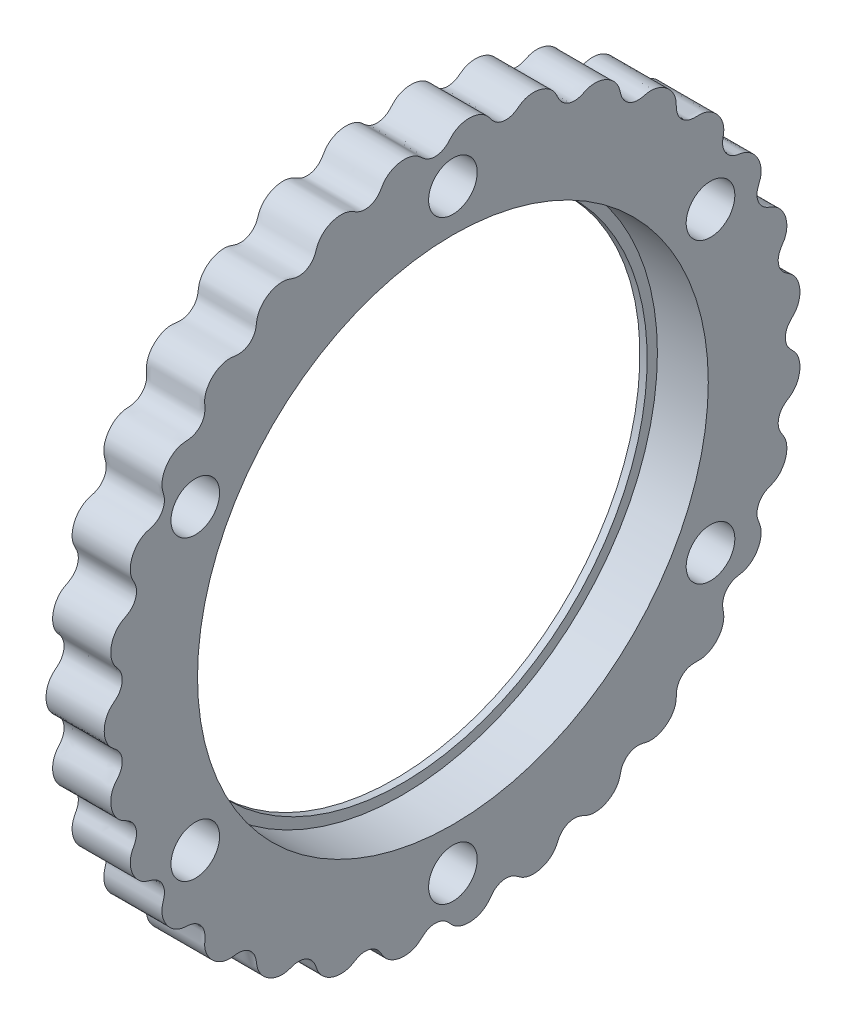
from build123d import *

# Parameters (mm, degrees)
BOSS_EXTRUDE1_START = 8.2233
SKETCH7_R           = 49.999999949
SKETCH7_R_2         = 4.7625
BOSS_EXTRUDE1_DEPTH = 11.38825


with BuildPart() as part:
    # Sketch6 → Revolve2 (revolve)
    with BuildSketch(Plane.XY):
        Polygon((19.611549931, 53.475999982), (19.611549931, 49.999999949), (9.651550039, 49.999999949), (9.651550039, 47.999999885), (8.223300038, 47.999999885), (8.223300038, 53.475999982), align=None)
    revolve(axis=Axis((0, 0, 0), (1, 0, 0)))

    # Sketch7 → Boss-Extrude1 (add)
    with BuildSketch(Plane(origin=(0, 0, 0), x_dir=(0, 0, -1), z_dir=(1, 0, 0)).offset(BOSS_EXTRUDE1_START)):
        with BuildLine():
            ThreePointArc((65.098780627, 0.27709471), (65.090321324, 0.138662117), (65.0875, 0))
            add(Edge.make_bspline(
                [(65.0875, 0), (65.0875, -0.208527214), (65.133599927, -0.609335641), (65.319634448, -1.45231409), (65.738958841, -2.044732783), (66.24197289, -2.634092343), (66.729882451, -3.091590187), (67.173103451, -3.625748901), (67.521923591, -4.256575501), (67.839915149, -5.13544118), (68.004224364, -6.262937423), (67.904252833, -7.395632118), (67.553421572, -8.463998502), (67.116556617, -9.243694687), (66.700058211, -9.785186855), (66.222308814, -10.231621663), (65.704158699, -10.582424575), (65.103322655, -10.967082845), (64.501549767, -11.498449482), (63.983590957, -12.254130319), (63.70763756, -13.098064846), (63.657719494, -13.866495058), (63.750855089, -14.554140201), (63.92789892, -15.134430068), (64.223112812, -15.709945145), (64.617055615, -16.274936704), (64.985907802, -16.884841215), (65.240485751, -17.579507616), (65.377214038, -18.331533392), (65.395270395, -19.11878896), (65.288777476, -19.945414815), (65.041620136, -20.788659452), (64.637922844, -21.623526922), (64.059495427, -22.401870056), (63.369916617, -23.037205503), (62.588760672, -23.470131774), (61.781981694, -23.746366631), (61.057767436, -24.118281418), (60.365794498, -24.706446383), (59.881634988, -25.407800925), (59.60933356, -26.15271169), (59.512709195, -26.91906777), (59.549810856, -27.588792892), (59.727266465, -28.278117532), (60.028942229, -28.968696408), (60.283097371, -29.702506941), (60.375831708, -30.502647102), (60.327159357, -31.328015311), (60.134956117, -32.157051395), (59.818344324, -32.932112808), (59.394478631, -33.638225664), (58.878075878, -34.262658017), (58.282418746, -34.791671978), (57.629949513, -35.20749347), (56.937792078, -35.491836111), (56.230514956, -35.633287995), (55.542462827, -35.743578453), (54.919227561, -35.945127455), (54.378361853, -36.235677848), (53.822571133, -36.664704513), (53.337918924, -37.227949926), (52.963453406, -37.963303629), (52.775433567, -38.847737386), (52.800223231, -39.694882195), (52.9662349, -40.433452061), (53.050052152, -41.095329294), (53.029920535, -41.674115611), (52.955631084, -42.160086027), (52.799880464, -42.75417159), (52.520389982, -43.437088414), (52.012298448, -44.274269508), (51.299918585, -45.032303579), (50.50742412, -45.599646966), (49.68883197, -45.974894374), (49.000137068, -46.172572319), (48.29403395, -46.238592897), (47.590293926, -46.202114971), (46.932560656, -46.210169697), (46.330103519, -46.323451249), (45.675208144, -46.561007427), (45.021374503, -46.957177111), (44.403479518, -47.583512755), (43.971316932, -48.390947227), (43.770608178, -49.182231329), (43.733836837, -49.918141941), (43.730202918, -50.581569376), (43.633360265, -51.260840719), (43.407861863, -51.935688033), (42.984623071, -52.755634025), (42.266810947, -53.65063513), (41.353321421, -54.359912682), (40.30073694, -54.836464715), (39.399602441, -55.039136925), (38.710911895, -55.087053199), (38.067869129, -55.022055726), (37.47907552, -54.881349135), (36.794495983, -54.723810858), (35.992455451, -54.67858833), (35.090739907, -54.852154256), (34.298120904, -55.264775421), (33.725724994, -55.77766287), (33.314091426, -56.326030843), (33.034525654, -56.85613165), (32.83918341, -57.464305795), (32.705345325, -58.131774444), (32.505687509, -58.807194553), (32.169196217, -59.456351497), (31.716094127, -60.059960046), (31.158665936, -60.602666075), (30.485664644, -61.08648281), (29.699854257, -61.483005172), (28.808796326, -61.758367993), (27.953871249, -61.85442347), (27.217642771, -61.814701517), (26.536609457, -61.672394232), (25.92357681, -61.438687439), (25.26563434, -61.097783124), (24.478749515, -60.847605456), (23.580552578, -60.780501103), (22.761380144, -60.934318086), (22.067821838, -61.253074418), (21.481129477, -61.693110247), (21.042659318, -62.158795665), (20.67642256, -62.733090561), (20.389603711, -63.396964652), (20.051827765, -64.082146621), (19.549758048, -64.716850032), (18.908353968, -65.275059777), (18.145176992, -65.733213948), (17.335448591, -66.049625736), (16.50728025, -66.230173936), (15.682009629, -66.28029119), (14.880324756, -66.203666598), (14.123036102, -66.005502475), (13.438659847, -65.683242084), (12.848906184, -65.253392751), (12.283807717, -64.832001483), (11.692774716, -64.53094275), (11.097457296, -64.353858192), (10.392650325, -64.267645052), (9.651170147, -64.3301147), (8.87454014, -64.590571684), (8.128950195, -65.079439494), (7.561609634, -65.679829469), (7.151583794, -66.297397585), (6.729156967, -66.799684612), (6.202825591, -67.255056705), (5.578332218, -67.647472205), (4.784057534, -67.978757441), (3.871203044, -68.170695106), (2.991682037, -68.20555347), (2.168553617, -68.109354915), (1.417994777, -67.905670937), (0.729030657, -67.598169147), (0.119777119, -67.19434149), (-0.382705821, -66.701157762), (-0.823475957, -66.182660164), (-1.288940213, -65.745522429), (-1.790185014, -65.417400832), (-2.415747125, -65.137226046), (-3.164826479, -64.965840346), (-4.058116602, -64.988777272), (-4.931137509, -65.273796164), (-5.611097561, -65.702088894), (-6.133610489, -66.172008004), (-6.580192909, -66.581134405), (-7.110874775, -66.950539519), (-7.736396728, -67.2432966), (-8.622903302, -67.503851726), (-9.774628476, -67.598343515), (-10.917604198, -67.421794177), (-11.979565302, -66.987958684), (-12.747454216, -66.476910694), (-13.272162733, -65.996720778), (-13.686698197, -65.450260943), (-14.01186638, -64.87225584), (-14.400653861, -64.246668794), (-14.959401472, -63.651961369), (-15.728508013, -63.155044879), (-16.572422434, -62.906398159), (-17.336447569, -62.876542133), (-18.024696272, -62.986078446), (-18.606813485, -63.178996407), (-19.186212177, -63.490911907), (-19.783960133, -63.864594593), (-20.433412148, -64.150058619), (-21.13167977, -64.311812333), (-22.029804988, -64.381326778), (-22.998248327, -64.270116742), (-23.98908353, -63.953282538), (-24.839662273, -63.468135869), (-25.415406877, -63.007008556), (-25.839922592, -62.56347311), (-26.140793251, -62.174887852), (-26.439449092, -61.67893544), (-26.687671118, -61.059919818), (-26.900717315, -60.33385226), (-27.289385435, -59.581036137), (-27.882148477, -58.898694182), (-28.676428001, -58.362013653), (-29.558759775, -58.086475817), (-30.441772143, -58.055434273), (-31.214462673, -58.206317436), (-31.86980159, -58.4437716), (-32.556985343, -58.663742727), (-33.300349404, -58.7514663), (-34.072911753, -58.704802119), (-34.850754916, -58.531519059), (-35.60550241, -58.236292929), (-36.318880143, -57.824765265), (-36.971873389, -57.300977958), (-37.542280155, -56.669743981), (-37.985506595, -55.972071723), (-38.29300378, -55.227828154), (-38.427324647, -54.463169768), (-38.498546343, -53.71314908), (-38.677348604, -53.024398049), (-38.969372424, -52.420760105), (-39.425101231, -51.797369791), (-40.024124338, -51.277707688), (-40.787472995, -50.898686955), (-41.677914418, -50.71943447), (-42.491963984, -50.745046394), (-43.331706344, -50.895182619), (-44.225096747, -50.896395561), (-45.136785204, -50.675815116), (-46.020688875, -50.27616239), (-46.779110165, -49.742190024), (-47.404600027, -49.124972807), (-47.898965605, -48.45411318), (-48.265328172, -47.757366122), (-48.510919379, -47.033826629), (-48.625808018, -46.303202682), (-48.599701057, -45.591156921), (-48.529358773, -44.90621679), (-48.550044659, -44.259964926), (-48.676326521, -43.66677007), (-48.927933882, -43.020317218), (-49.343792142, -42.372340431), (-49.994028128, -41.767670749), (-50.813366346, -41.357474339), (-51.597544294, -41.184145611), (-52.309804713, -41.139191117), (-52.933371259, -41.08421415), (-53.568084519, -40.926068976), (-54.195406571, -40.654922512), (-54.956216754, -40.185333104), (-55.781793395, -39.421553065), (-56.419088829, -38.479951793), (-56.822925434, -37.414500857), (-56.97164276, -36.492221529), (-56.973029477, -35.771847581), (-56.845636298, -35.089114075), (-56.643613582, -34.448226581), (-56.471149876, -33.722109144), (-56.45021147, -32.894815575), (-56.648988322, -32.009224627), (-57.12544295, -31.148664623), (-57.770816458, -30.510033855), (-58.483785298, -30.088598065), (-59.191456072, -29.849773218), (-59.842743593, -29.68225761), (-60.490317511, -29.429879454), (-61.101739119, -29.04797239), (-61.80671877, -28.433990043), (-62.49796599, -27.527866644), (-62.960463245, -26.489194084), (-63.172502852, -25.384969186), (-63.169243686, -24.491584285), (-63.06821848, -23.816216545), (-62.867622568, -23.194133856), (-62.585216527, -22.636034592), (-62.246501616, -22.008444784), (-61.977641103, -21.252337229), (-61.890647506, -20.340457494), (-62.058018119, -19.468502566), (-62.386639893, -18.771976392), (-62.801418631, -18.215369554), (-63.23763224, -17.793407343), (-63.774971539, -17.432942266), (-64.393759678, -17.129918901), (-65.012660975, -16.775882838), (-65.572817749, -16.292192684), (-66.05771389, -15.700985492), (-66.455904375, -15.021308586), (-66.764187565, -14.246832474), (-66.957505465, -13.389668656), (-67.009913235, -12.463993547), (-66.882274072, -11.503008018), (-66.588126935, -10.613071761), (-66.115924883, -9.855352976), (-65.544838391, -9.222463677), (-65.091731272, -8.546463101), (-64.771448831, -7.696797765), (-64.687670855, -6.848717016), (-64.810366014, -6.065040815), (-65.097254977, -5.347638583), (-65.454368055, -4.779633376), (-65.943819524, -4.262519157), (-66.542808083, -3.804890352), (-67.121614104, -3.286831794), (-67.591454137, -2.632274784), (-67.949821837, -1.886902764), (-68.184414509, -1.06859274), (-68.28393605, -0.237167433), (-68.256191437, 0.585925306), (-68.107930347, 1.382412123), (-67.84416715, 2.133869128), (-67.475853086, 2.81398793), (-67.009124824, 3.398576279), (-66.459786572, 3.86561719), (-65.911779637, 4.295672985), (-65.464463316, 4.773840889), (-65.132250985, 5.289920577), (-64.854010823, 5.93430364), (-64.702900712, 6.661731769), (-64.731513994, 7.486490506), (-64.995586877, 8.351430233), (-65.427923181, 9.080797368), (-65.931592436, 9.646299737), (-66.326562632, 10.184286247), (-66.590222117, 10.700151757), (-66.761376661, 11.1611903), (-66.913788227, 11.756358438), (-67.001102217, 12.489323034), (-66.96338589, 13.467987436), (-66.708639591, 14.476534554), (-66.291369554, 15.357152085), (-65.758188549, 16.082455013), (-65.252369093, 16.589563836), (-64.667485314, 16.990206207), (-64.034765873, 17.299861524), (-63.463597269, 17.625635387), (-62.991674485, 18.016513674), (-62.534053405, 18.541432856), (-62.154028174, 19.204646561), (-61.916831141, 20.051937153), (-61.929934043, 20.967801272), (-62.137840915, 21.757565907), (-62.462568686, 22.419283928), (-62.781619377, 23.001247236), (-63.02709929, 23.6422295), (-63.157823144, 24.341905866), (-63.186039006, 25.2645465), (-62.993064702, 26.395629377), (-62.538844822, 27.459206572), (-61.850151852, 28.386770082), (-61.161106956, 29.001321708), (-60.582630951, 29.377570314), (-59.989264233, 29.633091123), (-59.406502947, 29.795948992), (-58.731661292, 29.990064037), (-58.008389087, 30.338955379), (-57.303706923, 30.927557951), (-56.81013598, 31.672471006), (-56.557792477, 32.398563602), (-56.463350547, 33.077941317), (-56.475675348, 33.677329124), (-56.599616303, 34.304195513), (-56.806551591, 34.95297408), (-56.960234026, 35.640560717), (-56.981455999, 36.371682952), (-56.878461457, 37.119663043), (-56.654609109, 37.864967955), (-56.301088968, 38.61504515), (-55.806657996, 39.342459185), (-55.161426724, 40.017503659), (-54.361014049, 40.583897815), (-53.496595924, 40.977336601), (-52.607515966, 41.136604478), (-51.744629659, 41.158154435), (-50.935367343, 41.321670598), (-50.117283309, 41.697616446), (-49.475182428, 42.229209504), (-49.022813994, 42.844051931), (-48.722706685, 43.513467734), (-48.564782896, 44.133475745), (-48.522736931, 44.813521087), (-48.593968279, 45.533384377), (-48.631594221, 46.296591146), (-48.501026247, 47.095498608), (-48.211318273, 47.895204571), (-47.766482722, 48.666538452), (-47.212119151, 49.336405058), (-46.575745454, 49.896331925), (-45.878698109, 50.340761131), (-45.140880524, 50.662952138), (-44.382893009, 50.857408667), (-43.628373449, 50.908166372), (-42.904317129, 50.818882237), (-42.205983534, 50.724467099), (-41.543332646, 50.747553086), (-40.93697503, 50.881093834), (-40.278774918, 51.147092355), (-39.726177254, 51.51709253), (-39.265759426, 51.989317362), (-38.913097442, 52.536412531), (-38.700129023, 53.002265802), (-38.549899911, 53.511264182), (-38.463898812, 54.054621293), (-38.403502395, 54.621737587), (-38.285026171, 55.198685163), (-38.0676823, 55.778416951), (-37.755900982, 56.3460708), (-37.353609085, 56.888235655), (-36.860839393, 57.390707355), (-36.291994627, 57.835307839), (-35.652989595, 58.209263689), (-34.951059685, 58.498307018), (-34.196279128, 58.684637227), (-33.444956267, 58.750386141), (-32.716497281, 58.693378397), (-32.037925098, 58.50649809), (-31.401134038, 58.267106033), (-30.782351649, 58.110395605), (-30.185106483, 58.06627521), (-29.502243493, 58.124232235), (-28.884851365, 58.302450562), (-28.318947446, 58.598494194), (-27.827548041, 58.994688521), (-27.487837712, 59.359718588), (-27.186738845, 59.790527193), (-26.940422015, 60.284195953), (-26.751291282, 60.831180957), (-26.559536092, 61.405971294), (-26.275089728, 61.9869361), (-25.870348067, 62.546905303), (-25.221676678, 63.205446613), (-24.260583478, 63.847362207), (-23.175634834, 64.247962632), (-22.036744191, 64.384317334), (-21.117636971, 64.31050965), (-20.425994674, 64.145690554), (-19.798389308, 63.869574583), (-19.233690748, 63.522277275), (-18.590599397, 63.163742385), (-17.813982686, 62.914335545), (-16.900566218, 62.852231134), (-16.041862981, 63.043466839), (-15.358901381, 63.387510255), (-14.809698908, 63.816957127), (-14.393815212, 64.267966142), (-14.038122504, 64.821855528), (-13.696837114, 65.438967111), (-13.267748687, 66.004208978), (-12.735744996, 66.484915586), (-11.984128115, 66.981997762), (-11.083350893, 67.355058748), (-10.063288348, 67.559137094), (-9.084232922, 67.54798907), (-8.357254399, 67.424489182), (-7.770963145, 67.24299115), (-7.319382673, 67.049516231), (-6.817584442, 66.761196304), (-6.300071331, 66.340896897), (-5.761725636, 65.809560927), (-5.05727268, 65.339538804), (-4.208279941, 65.029876241), (-3.253443051, 64.945123001), (-2.347912411, 65.131555259), (-1.560194315, 65.532410682), (-0.957216653, 66.039045289), (-0.499165147, 66.564746927), (-0.005177931, 67.09099361), (0.602161034, 67.528918613), (1.300410473, 67.863409544), (2.06478268, 68.089696467), (2.868072177, 68.19805745), (3.691532695, 68.184626118), (4.516579485, 68.043769503), (5.321498321, 67.768992121), (6.047538655, 67.37445946), (6.677640825, 66.873407548), (7.166402525, 66.2704743), (7.592442055, 65.649354287), (8.082493095, 65.133711315), (8.63031314, 64.747320209), (9.33083286, 64.422909482), (10.106523713, 64.258537947), (10.957961318, 64.2967675), (11.823881433, 64.571454232), (12.523839877, 64.988489381), (13.185388879, 65.527536564), (13.965873156, 65.962865382), (14.870296559, 66.212889219), (15.83737364, 66.29277617), (16.75984855, 66.194168587), (17.606359658, 65.958245411), (18.364149921, 65.611831723), (19.022521946, 65.18078122), (19.588377632, 64.667732785), (20.043566443, 64.085106699), (20.366545989, 63.450259915), (20.63725125, 62.817413601), (20.968429565, 62.262354037), (21.366205034, 61.804808088), (21.899337743, 61.361350658), (22.576945293, 60.995981485), (23.438732094, 60.781945837), (24.354354495, 60.820055188), (25.124617066, 61.048463747), (25.769517883, 61.354746725), (26.341516763, 61.609681427), (26.973356225, 61.779898169), (27.653674932, 61.847601463), (28.547130208, 61.806557145), (29.639852185, 61.539673345), (30.654161912, 61.025921508), (31.524424837, 60.290662795), (32.102102301, 59.556920579), (32.453094234, 58.928135215), (32.673385666, 58.269743208), (32.807811299, 57.61161188), (33.008866039, 56.893179091), (33.391244061, 56.159625864), (33.994050448, 55.481303137), (34.827713804, 54.959214129), (35.701832419, 54.713126285), (36.530043381, 54.689906964), (37.26506112, 54.824099151), (37.916033657, 54.993851192), (38.60490424, 55.08793076), (39.325116472, 55.051074478), (40.239879796, 54.856636307), (41.284264472, 54.400074327), (42.19288626, 53.716595309), (42.914311438, 52.854338177), (43.345152721, 52.072082162), (43.584779045, 51.432906805), (43.711642276, 50.791962101), (43.735870932, 50.167199818), (43.744089088, 49.45434592), (43.875191803, 48.662954485), (44.240818491, 47.823212576), (44.809589922, 47.141480279), (45.434579665, 46.691266567), (46.067312982, 46.405218375), (46.653564918, 46.247431711), (47.298509953, 46.192527021), (47.98683797, 46.227771019), (48.700033595, 46.218971017), (49.424859979, 46.06824357), (50.136095657, 45.786806713), (50.814454365, 45.385852285), (51.460076072, 44.858382141), (52.045218817, 44.202895538), (52.540363502, 43.419251201), (52.895328728, 42.517489825), (53.070319359, 41.597040529), (53.025829888, 40.705627676), (52.83379449, 39.875385295), (52.765039494, 39.064809426), (52.896538829, 38.166495639), (53.234090261, 37.3840187), (53.721158686, 36.75781677), (54.319899289, 36.26913087), (54.907704197, 35.945253966), (55.586658297, 35.730074338), (56.332650091, 35.620476415), (57.090450508, 35.44881366), (57.819284464, 35.104770237), (58.494722275, 34.627072057), (59.097319405, 34.025438254), (59.588061297, 33.346797153), (59.963412405, 32.61375127), (60.22045987, 31.845582219), (60.354722446, 31.060835616), (60.363028285, 30.287698597), (60.239087823, 29.550227579), (59.985858369, 28.875375865), (59.715335504, 28.233692951), (59.555854255, 27.598874401), (59.51535053, 26.986656548), (59.584136988, 26.288376247), (59.804304586, 25.578894087), (60.228878785, 24.8711802), (60.879060283, 24.24237152), (61.610972483, 23.813630134), (62.326016313, 23.563392409), (62.9328351, 23.284956444), (63.414061105, 22.962016908), (63.787724235, 22.642031658), (64.210137091, 22.195623384), (64.64252785, 21.597067029), (65.084762266, 20.723103401), (65.351710938, 19.717736121), (65.414492742, 18.745452613), (65.300658682, 17.85279884), (65.104873731, 17.16409243), (64.78843147, 16.529954453), (64.385763434, 15.952270489), (64.044245189, 15.390654814), (63.820928032, 14.820272353), (63.674993876, 14.139613382), (63.66381178, 13.375434743), (63.866718082, 12.519242329), (64.321945057, 11.724251252), (64.886707068, 11.133881523), (65.491745666, 10.712395996), (66.053430871, 10.358403908), (66.579606541, 9.917281221), (67.033886666, 9.368982825), (67.506781805, 8.575849259), (67.887322059, 7.493237369), (68.006620853, 6.342877099), (67.854962709, 5.197805638), (67.551188332, 4.326234505), (67.228431214, 3.71663637), (66.834148309, 3.205594474), (66.403891124, 2.779295127), (65.995920437, 2.36835207), (65.660759281, 1.938279066), (65.405507552, 1.483873124), (65.222631392, 0.981968459), (65.137102603, 0.598793939), (65.107445539, 0.38335928), (65.098780627, 0.27709471)],
                knots=[0.070150854, 0.070150854, 0.070150854, 0.070150854, 0.070150854, 0.071893071, 0.073635288, 0.074838597, 0.076041906, 0.077245214, 0.078448523, 0.079817628, 0.081186732, 0.083924941, 0.086561309, 0.087879492, 0.089197676, 0.090319309, 0.091440942, 0.092562576, 0.093684209, 0.095430801, 0.097177394, 0.099042582, 0.099975177, 0.100907771, 0.102140996, 0.103374221, 0.104607446, 0.105840671, 0.107249061, 0.10865745, 0.11006584, 0.111474229, 0.113208606, 0.114942982, 0.116677358, 0.118411735, 0.11986725, 0.121322765, 0.12277828, 0.124233795, 0.126319913, 0.127362972, 0.128406031, 0.129754508, 0.131102986, 0.132451463, 0.133799941, 0.135320288, 0.136840636, 0.138360984, 0.139881331, 0.141306064, 0.142730796, 0.144155528, 0.14558026, 0.146828111, 0.148075961, 0.149323812, 0.150571662, 0.151515086, 0.152458509, 0.154345355, 0.155856844, 0.157368332, 0.158879821, 0.160391309, 0.16127117, 0.162151032, 0.163030893, 0.163910754, 0.165670476, 0.167430198, 0.170021752, 0.171317529, 0.172613306, 0.173874545, 0.175135783, 0.176397021, 0.17765826, 0.178588335, 0.17951841, 0.18137856, 0.183098218, 0.184817876, 0.186005662, 0.187193449, 0.188381236, 0.189569023, 0.190921475, 0.192273928, 0.194978833, 0.197738641, 0.199118545, 0.200498449, 0.20158315, 0.202667851, 0.203752553, 0.204837254, 0.20661968, 0.208402107, 0.210245056, 0.211166531, 0.212088006, 0.213306778, 0.21452555, 0.215744321, 0.216963093, 0.218354443, 0.219745793, 0.221137143, 0.222528493, 0.224283311, 0.22603813, 0.227792948, 0.228670357, 0.229547767, 0.231022285, 0.232496803, 0.233971322, 0.23544584, 0.237420346, 0.2384076, 0.239394853, 0.240689479, 0.241984106, 0.243278733, 0.24457336, 0.246163811, 0.247754262, 0.249344714, 0.250935165, 0.252375456, 0.253815746, 0.255256037, 0.256696328, 0.25795886, 0.259221392, 0.260483924, 0.261746456, 0.262700388, 0.263654321, 0.265562186, 0.267037264, 0.268512343, 0.269987422, 0.271462501, 0.272340201, 0.273217901, 0.2749733, 0.2767287, 0.2784841, 0.279874956, 0.281265812, 0.282656668, 0.284047523, 0.285265888, 0.286484252, 0.287702617, 0.288920981, 0.289842135, 0.290763289, 0.292605598, 0.294388462, 0.296171325, 0.297256526, 0.298341726, 0.299426927, 0.300512127, 0.301892535, 0.303272943, 0.306033758, 0.308737708, 0.310089683, 0.311441658, 0.312629014, 0.31381637, 0.315003726, 0.316191082, 0.317910089, 0.319629096, 0.321489951, 0.322420379, 0.323350807, 0.324612493, 0.325874178, 0.327135864, 0.32839755, 0.32969376, 0.330989971, 0.333582392, 0.335341521, 0.337100651, 0.337980216, 0.338859781, 0.339739346, 0.340618911, 0.342129817, 0.343640723, 0.345151629, 0.346662535, 0.348549989, 0.350437443, 0.351685711, 0.352933979, 0.354182247, 0.355430515, 0.356855701, 0.358280887, 0.359706074, 0.36113126, 0.362651165, 0.364171071, 0.365690976, 0.367210882, 0.368558994, 0.369907105, 0.371255217, 0.372603329, 0.373646093, 0.374688857, 0.376774385, 0.378230422, 0.379686459, 0.381142496, 0.382598533, 0.384333491, 0.386068449, 0.387803407, 0.389538365, 0.390946279, 0.392354193, 0.393762106, 0.39517002, 0.396402831, 0.397635641, 0.398868452, 0.400101263, 0.401033545, 0.401965826, 0.40383039, 0.405577537, 0.407324685, 0.408446761, 0.409568837, 0.410690914, 0.41181299, 0.413131656, 0.414450321, 0.417087652, 0.419824921, 0.421193555, 0.42256219, 0.423765048, 0.424967907, 0.426170765, 0.427373623, 0.429115206, 0.430856788, 0.432599639, 0.434342489, 0.435546249, 0.436750009, 0.437953769, 0.439157529, 0.440527103, 0.441896677, 0.444635826, 0.44727123, 0.448588932, 0.449906634, 0.451027825, 0.452149017, 0.453270208, 0.4543914, 0.456137435, 0.457883471, 0.459749285, 0.460682191, 0.461615098, 0.462848737, 0.464082377, 0.465316016, 0.466549656, 0.46795852, 0.469367385, 0.47077625, 0.472185115, 0.473918909, 0.475652704, 0.477386499, 0.479120294, 0.480575288, 0.482030282, 0.483485276, 0.484940271, 0.487026977, 0.48807033, 0.489113683, 0.490462527, 0.491811371, 0.493160214, 0.494509058, 0.496029847, 0.497550636, 0.499071425, 0.500592214, 0.502016491, 0.503440769, 0.504865047, 0.506289324, 0.507536757, 0.508784191, 0.510031624, 0.511279057, 0.512222176, 0.513165295, 0.515051534, 0.516563605, 0.518075677, 0.519587749, 0.521099821, 0.521979978, 0.522860136, 0.523740293, 0.52462045, 0.526380765, 0.52814108, 0.530731766, 0.532027109, 0.533322453, 0.534583244, 0.535844035, 0.537104827, 0.538365618, 0.53929534, 0.540225062, 0.542084506, 0.543804814, 0.545525122, 0.546713341, 0.547901559, 0.549089778, 0.550277996, 0.551630926, 0.552983856, 0.555689715, 0.558448515, 0.559827915, 0.561207315, 0.562291519, 0.563375723, 0.564459926, 0.56554413, 0.567326117, 0.569108104, 0.570951695, 0.57187349, 0.572795285, 0.574014464, 0.575233644, 0.576452823, 0.577672003, 0.579063846, 0.58045569, 0.581847533, 0.583239377, 0.584993614, 0.586747851, 0.588502088, 0.590256325, 0.591730284, 0.593204243, 0.594678202, 0.596152161, 0.598127253, 0.5991148, 0.600102346, 0.601397327, 0.602692308, 0.603987289, 0.60528227, 0.606873215, 0.60846416, 0.610055104, 0.611646049, 0.613085909, 0.614525768, 0.615965628, 0.617405487, 0.618667601, 0.619929715, 0.621191829, 0.622453943, 0.623407582, 0.62436122, 0.626268497, 0.627184411, 0.628100325, 0.629016239, 0.629932154, 0.630988824, 0.632045495, 0.633102166, 0.634158836, 0.635417997, 0.636677157, 0.637936318, 0.639195478, 0.640585839, 0.641976201, 0.643366562, 0.644756923, 0.64597488, 0.647192838, 0.648410795, 0.649628752, 0.650549586, 0.651470419, 0.653312085, 0.654203735, 0.655095385, 0.655987034, 0.656878684, 0.657964385, 0.659050086, 0.660135787, 0.661221488, 0.6626024, 0.663983311, 0.666745134, 0.669448129, 0.670799626, 0.672151124, 0.673338049, 0.674524975, 0.675711901, 0.676898826, 0.678617182, 0.680335537, 0.682197097, 0.683127878, 0.684058658, 0.685320792, 0.686582925, 0.687845059, 0.689107192, 0.690403836, 0.691700479, 0.694293766, 0.696052304, 0.697810841, 0.69869011, 0.699569379, 0.700448648, 0.701327916, 0.702838241, 0.704348565, 0.70585889, 0.707369214, 0.709257275, 0.711145336, 0.712394021, 0.713642707, 0.714891392, 0.716140078, 0.717565717, 0.718991357, 0.720416997, 0.721842636, 0.723362099, 0.724881561, 0.726401024, 0.727920487, 0.729268233, 0.730615978, 0.731963724, 0.73331147, 0.734353939, 0.735396408, 0.737481346, 0.738937905, 0.740394465, 0.741851025, 0.743307585, 0.745043125, 0.746778664, 0.748514204, 0.750249744, 0.751657181, 0.753064619, 0.754472056, 0.755879494, 0.75711189, 0.758344287, 0.759576683, 0.76080908, 0.761741049, 0.762673018, 0.764536956, 0.766284656, 0.768032357, 0.769154878, 0.770277399, 0.77139992, 0.772522441, 0.773841588, 0.775160735, 0.77779903, 0.780535358, 0.781903523, 0.783271687, 0.784474095, 0.785676503, 0.786878911, 0.788081319, 0.789822267, 0.791563215, 0.793306699, 0.795050183, 0.796254395, 0.797458606, 0.798662818, 0.799867029, 0.801237073, 0.802607116, 0.805347203, 0.807981644, 0.809298865, 0.810616085, 0.811736836, 0.812857588, 0.813978339, 0.81509909, 0.816844568, 0.818590045, 0.820456482, 0.821389701, 0.82232292, 0.823556974, 0.824791028, 0.826025082, 0.827259136, 0.828668475, 0.830077815, 0.831487154, 0.832896493, 0.834629707, 0.83636292, 0.838096133, 0.839829346, 0.841283821, 0.842738295, 0.84419277, 0.845647245, 0.847734538, 0.848778185, 0.849821832, 0.851171042, 0.852520251, 0.853869461, 0.855218671, 0.8567399, 0.85826113, 0.85978236, 0.86130359, 0.862727412, 0.864151234, 0.865575057, 0.866998879, 0.868245895, 0.869492911, 0.870739926, 0.871986942, 0.872929757, 0.873872572, 0.875758202, 0.877270858, 0.878783514, 0.88029617, 0.881808826, 0.88268928, 0.883569733, 0.884450187, 0.88533064, 0.887091547, 0.888852454, 0.891442273, 0.892737182, 0.894032091, 0.895292436, 0.896552781, 0.897813125, 0.89907347, 0.900002838, 0.900932207, 0.902790944, 0.904511902, 0.90623286, 0.907421511, 0.908610162, 0.909798812, 0.910987463, 0.91234087, 0.913694277, 0.916401091, 0.919158883, 0.920537779, 0.921916675, 0.923000383, 0.92408409, 0.925167798, 0.926251505, 0.927142278, 0.928033051, 0.928923824, 0.929814596, 0.929814596, 0.929814596, 0.929814596, 0.929814596], degree=4))
        make_face()
        Circle(SKETCH7_R, mode=Mode.SUBTRACT)
        with Locations((-50.436020463, -29.119249991)):
            Circle(SKETCH7_R_2, mode=Mode.SUBTRACT)
        with Locations((0, -58.238499982)):
            Circle(SKETCH7_R_2, mode=Mode.SUBTRACT)
        with Locations((50.436020463, -29.119249991)):
            Circle(SKETCH7_R_2, mode=Mode.SUBTRACT)
        with Locations((50.436020463, 29.119249991)):
            Circle(SKETCH7_R_2, mode=Mode.SUBTRACT)
        with Locations((0, 58.238499982)):
            Circle(SKETCH7_R_2, mode=Mode.SUBTRACT)
        with Locations((-50.436020463, 29.119249991)):
            Circle(SKETCH7_R_2, mode=Mode.SUBTRACT)
    extrude(amount=BOSS_EXTRUDE1_DEPTH)


solid = part.part
